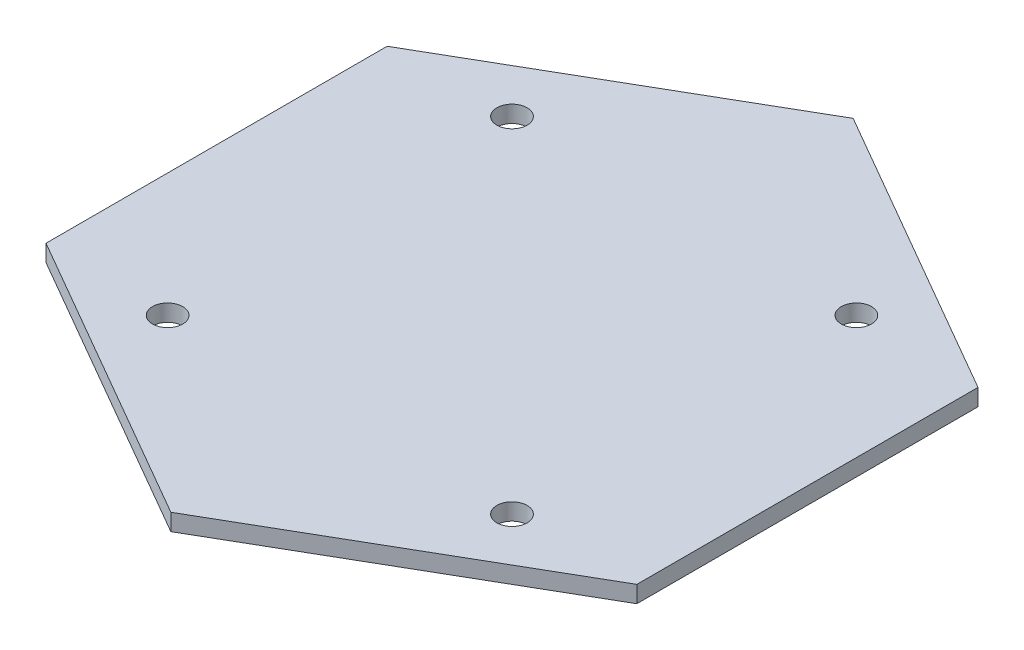
from build123d import *

# Parameters (mm, degrees)
SKETCH1_R           = 2.286
BOSS_EXTRUDE1_DEPTH = 2.54
SKETCH2_R           = 11.684
SKETCH2_R_2         = 9.906
BOSS_EXTRUDE2_DEPTH = 15.875
FILLET1_R           = 3.175
SWEEP2_PITCH        = 5.08
SWEEP2_HEIGHT       = 14.224
SWEEP2_RADIUS       = 9.906
SWEEP2_START_ANGLE  = -90


with BuildPart() as part:
    # Sketch1 → Boss-Extrude1 (new body)
    with BuildSketch(Plane(origin=(0, 0, 0), x_dir=(1, 0, 0), z_dir=(0, 1, 0))):
        Polygon((0, 51.579152228), (-44.668856135, 25.789576114), (-44.668856135, -25.789576114), (0, -51.579152228), (44.668856135, -25.789576114), (44.668856135, 25.789576114), align=None)
        with Locations((-26.035, 26.035)):
            Circle(SKETCH1_R, mode=Mode.SUBTRACT)
        with Locations((26.035, 26.035)):
            Circle(SKETCH1_R, mode=Mode.SUBTRACT)
        with Locations((26.035, -26.035)):
            Circle(SKETCH1_R, mode=Mode.SUBTRACT)
        with Locations((-26.035, -26.035)):
            Circle(SKETCH1_R, mode=Mode.SUBTRACT)
    extrude(amount=BOSS_EXTRUDE1_DEPTH)

    # Sketch2 → Boss-Extrude2 (add)
    with BuildSketch(Plane.XZ):
        Circle(SKETCH2_R)
        Circle(SKETCH2_R_2, mode=Mode.SUBTRACT)
    extrude(amount=BOSS_EXTRUDE2_DEPTH)

    # Fillet1
    fillet1_edges = [part.edges().sort_by_distance(p)[0] for p in [
        (-11.684, 0, 0),
    ]]
    fillet(fillet1_edges, radius=FILLET1_R)


with BuildPart() as body_2:
    # Sweep2: sweep along a helix
    with BuildLine() as sweep2_path:
        add(Helix(SWEEP2_PITCH, SWEEP2_HEIGHT, SWEEP2_RADIUS, center=(0, 0, 0), direction=(0, -1, 0), mode=Mode.PRIVATE).rotate(Axis((0, 0, 0), (0, -1, 0)), SWEEP2_START_ANGLE))
    # Sketch4 → Sweep2 (sweep)
    with BuildSketch(Plane.XY):
        Polygon((-9.906, -1.524), (-8.128, -1.4224), (-8.128, -0.1016), (-9.906, 0), align=None)
    sweep(path=sweep2_path.line, is_frenet=True)


solid = Compound([part.part, body_2.part])
